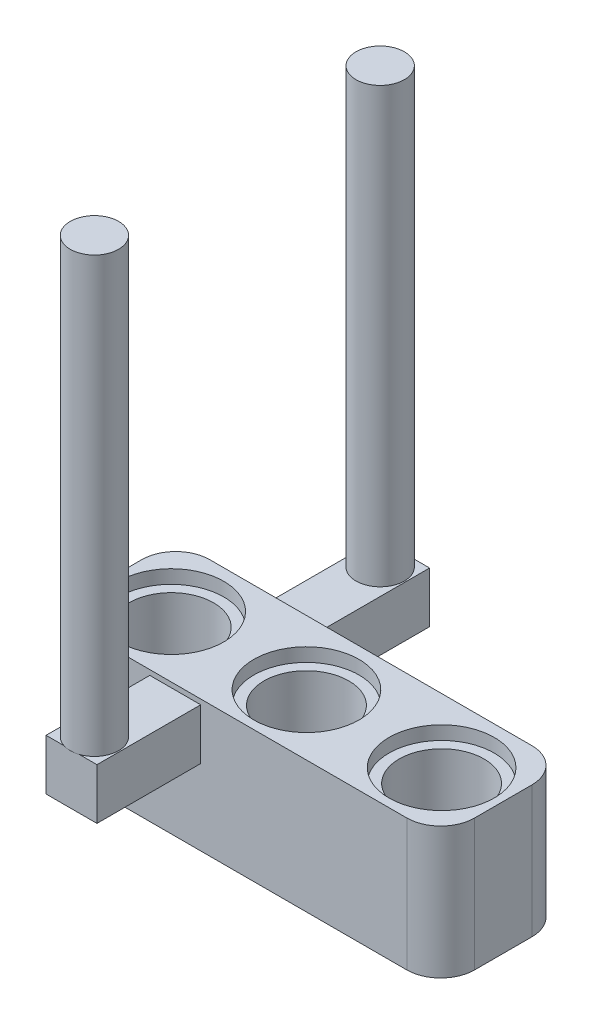
from build123d import *

# Parameters (mm, degrees)
SKETCH3_W           = 23
SKETCH3_H           = 7.38
BOSS_EXTRUDE1_DEPTH = 7.76
SKETCH4_R           = 3.1
CUT_EXTRUDE2_DEPTH  = 0.8
SKETCH7_R           = 3.1
CUT_EXTRUDE3_DEPTH  = 0.8
SKETCH6_R           = 2.5
CUT_EXTRUDE4_DEPTH  = 7.96
FILLET3_R           = 2
FILLET4_R           = 2
FILLET5_R           = 2
FILLET6_R           = 2
SKETCH8_W           = 3
SKETCH8_H           = 3
BOSS_EXTRUDE2_DEPTH = 6.115
SKETCH9_R           = 1.425
BOSS_EXTRUDE3_DEPTH = 25.6
SKETCH12_W          = 3
SKETCH12_H          = 3
BOSS_EXTRUDE4_DEPTH = 6.115
SKETCH13_R          = 1.425
BOSS_EXTRUDE5_DEPTH = 25.6


with BuildPart() as part:
    # Sketch3 → Boss-Extrude1 (new body)
    with BuildSketch(Plane(origin=(0, 0, 0), x_dir=(1, 0, 0), z_dir=(0, 1, 0))):
        with Locations((-11.5, 3.69)):
            Rectangle(SKETCH3_W, SKETCH3_H)
    extrude(amount=BOSS_EXTRUDE1_DEPTH)

    # Sketch4 → Cut-Extrude2 (cut)
    with BuildSketch(Plane(origin=(0, 0, 0), x_dir=(-1, 0, 0), z_dir=(0, -1, 0))):
        with Locations((19.538269405, 3.69)):
            Circle(SKETCH4_R)
        with Locations((11.538269405, 3.69)):
            Circle(SKETCH4_R)
        with Locations((3.538269405, 3.69)):
            Circle(SKETCH4_R)
    extrude(amount=-CUT_EXTRUDE2_DEPTH, mode=Mode.SUBTRACT)

    # Sketch7 → Cut-Extrude3 (cut)
    with BuildSketch(Plane(origin=(0, 7.76, 0), x_dir=(1, 0, 0), z_dir=(0, 1, 0))):
        with Locations((-19.478269405, 3.591470107)):
            Circle(SKETCH7_R)
        with Locations((-11.508269405, 3.591470107)):
            Circle(SKETCH7_R)
        with Locations((-3.538269405, 3.591470107)):
            Circle(SKETCH7_R)
    extrude(amount=-CUT_EXTRUDE3_DEPTH, mode=Mode.SUBTRACT)

    # Sketch6 → Cut-Extrude4 (cut, through all)
    with BuildSketch(Plane(origin=(0, 0.8, 0), x_dir=(-1, 0, 0), z_dir=(0, -1, 0))):
        with Locations((3.538269405, 3.591470107)):
            Circle(SKETCH6_R)
        with Locations((11.508269405, 3.591470107)):
            Circle(SKETCH6_R)
        with Locations((19.478269405, 3.591470107)):
            Circle(SKETCH6_R)
    extrude(amount=-CUT_EXTRUDE4_DEPTH, mode=Mode.SUBTRACT)

    # Fillet3
    fillet3_edges = [part.edges().sort_by_distance(p)[0] for p in [
        (0, 3.88, 0),
    ]]
    fillet(fillet3_edges, radius=FILLET3_R)

    # Fillet4
    fillet4_edges = [part.edges().sort_by_distance(p)[0] for p in [
        (-23, 3.88, 0),
    ]]
    fillet(fillet4_edges, radius=FILLET4_R)

    # Fillet5
    fillet5_edges = [part.edges().sort_by_distance(p)[0] for p in [
        (-23, 3.88, -7.38),
    ]]
    fillet(fillet5_edges, radius=FILLET5_R)

    # Fillet6
    fillet6_edges = [part.edges().sort_by_distance(p)[0] for p in [
        (0, 3.88, -7.38),
    ]]
    fillet(fillet6_edges, radius=FILLET6_R)

    # Sketch8 → Boss-Extrude2 (add)
    with BuildSketch(Plane(origin=(0, 0, -7.38), x_dir=(-1, 0, 0), z_dir=(0, 0, -1))):
        with Locations((15.65, 6.200251459)):
            Rectangle(SKETCH8_W, SKETCH8_H)
    extrude(amount=BOSS_EXTRUDE2_DEPTH)

    # Sketch9 → Boss-Extrude3 (add)
    with BuildSketch(Plane(origin=(0, 7.700251459, 0), x_dir=(1, 0, 0), z_dir=(0, 1, 0))):
        with Locations((-15.65, 12.081963091)):
            Circle(SKETCH9_R)
    extrude(amount=BOSS_EXTRUDE3_DEPTH)

    # Sketch12 → Boss-Extrude4 (add)
    with BuildSketch(Plane.XY):
        with Locations((-15.65, 5.962808026)):
            Rectangle(SKETCH12_W, SKETCH12_H)
    extrude(amount=BOSS_EXTRUDE4_DEPTH)

    # Sketch13 → Boss-Extrude5 (add)
    with BuildSketch(Plane(origin=(0, 7.462808026, 0), x_dir=(1, 0, 0), z_dir=(0, 1, 0))):
        with Locations((-15.65, -4.763284268)):
            Circle(SKETCH13_R)
    extrude(amount=BOSS_EXTRUDE5_DEPTH)


solid = part.part
